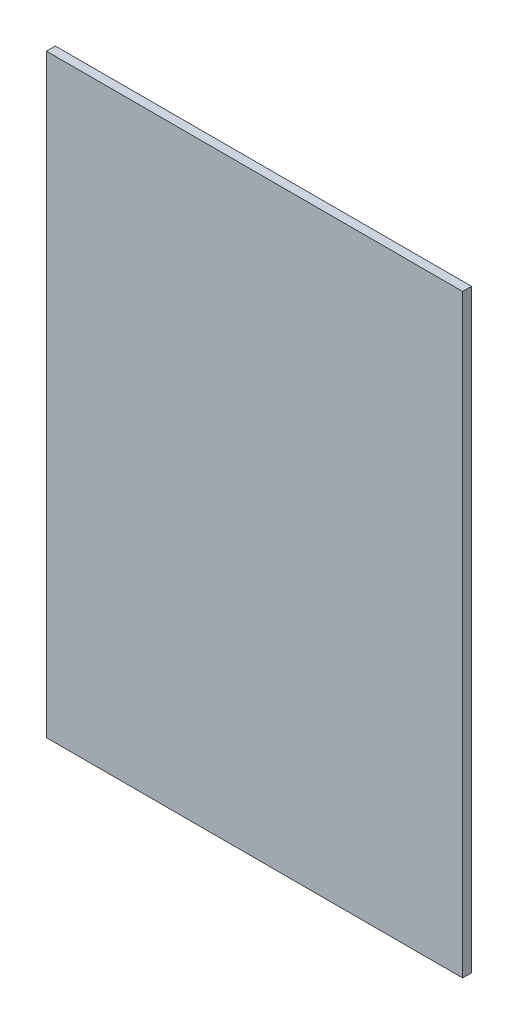
from build123d import *

# Parameters (mm, degrees)
SKETCH1_W           = 1400
SKETCH1_H           = 2000
BOSS_EXTRUDE1_DEPTH = 30


with BuildPart() as part:
    # Sketch1 → Boss-Extrude1 (new body)
    with BuildSketch(Plane.XY):
        Rectangle(SKETCH1_W, SKETCH1_H)
    extrude(amount=BOSS_EXTRUDE1_DEPTH)


solid = part.part
